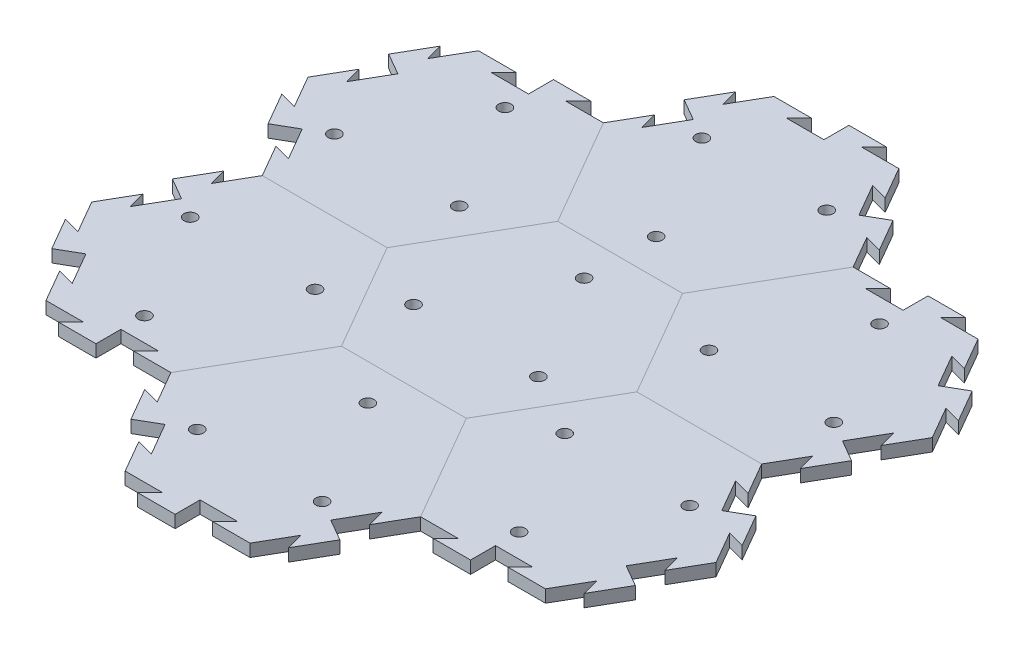
from build123d import *

# Parameters (mm, degrees)
BOSS_EXTRUDE1_DEPTH = 6.35
SKETCH9_R           = 3.175
CUT_EXTRUDE3_DEPTH  = 7.35
CIRPATTERN6_COUNT   = 3
CUT_EXTRUDE2_DEPTH  = 7.35
BOSS_EXTRUDE3_DEPTH = 6.35
CIRPATTERN3_COUNT   = 3
CIRPATTERN3_ANGLE   = 120
CIRPATTERN5_COUNT   = 6


with BuildPart() as part:
    # Sketch1 → Boss-Extrude1 (new body)
    with BuildSketch(Plane(origin=(0, 0, 0), x_dir=(1, 0, 0), z_dir=(0, 1, 0))):
        Polygon((63.5, 0), (31.75, 54.99261314), (-31.75, 54.99261314), (-63.5, 0), (-31.75, -54.99261314), (31.75, -54.99261314), align=None)
    extrude(amount=-BOSS_EXTRUDE1_DEPTH)

    # Sketch9 → Cut-Extrude3 (cut, through all)
    with BuildSketch(Plane(origin=(0, 0, 0), x_dir=(1, 0, 0), z_dir=(0, 1, 0))):
        with Locations((-31.75, -18.330871047)):
            Circle(SKETCH9_R)
    cut_extrude3 = extrude(amount=-CUT_EXTRUDE3_DEPTH, mode=Mode.SUBTRACT)

    # CirPattern6: Cut-Extrude3 ×3 about axis
    cirpattern6_axis = Axis((0, 0, 0), (0, 1, 0))
    for i in range(1, CIRPATTERN6_COUNT):
        add(cut_extrude3.rotate(cirpattern6_axis, i * 360 / CIRPATTERN6_COUNT), mode=Mode.SUBTRACT)


with BuildPart() as body_2:
    # Mirror1: mirrored copy
    add(part.part.mirror(Plane(origin=(31.75, -6.35, 54.99261314), x_dir=(-0.5, 0, 0.866025404), z_dir=(0.866025404, 0, 0.5))))

    # Sketch5 → Cut-Extrude2 (cut, through all)
    with BuildSketch(Plane(origin=(0, 0, 0), x_dir=(1, 0, 0), z_dir=(0, 1, 0))):
        Polygon((136.525, -16.497783942), (127.850738686, -14.173522628), (137.375738686, -30.67130657), (142.875, -27.49630657), align=None)
    cut_extrude2 = extrude(amount=-CUT_EXTRUDE2_DEPTH, mode=Mode.SUBTRACT)

    # Sketch7 → Boss-Extrude3 (add)
    with BuildSketch(Plane(origin=(0, 0, 0), x_dir=(1, 0, 0), z_dir=(0, 1, 0))):
        Polygon((142.875, -27.49630657), (148.374261314, -24.32130657), (157.899261314, -40.819090512), (149.225, -38.494829198), align=None)
    boss_extrude3 = extrude(amount=-BOSS_EXTRUDE3_DEPTH)

    # CirPattern3: Cut-Extrude2, Boss-Extrude3 ×3 about axis
    cirpattern3_axis = Axis((95.25, 0, 54.99261314), (0, -1, 0))
    for i in range(1, CIRPATTERN3_COUNT):
        add(cut_extrude2.rotate(cirpattern3_axis, i * CIRPATTERN3_ANGLE / (CIRPATTERN3_COUNT - 1)), mode=Mode.SUBTRACT)
        add(boss_extrude3.rotate(cirpattern3_axis, i * CIRPATTERN3_ANGLE / (CIRPATTERN3_COUNT - 1)))


with BuildPart() as cirpattern5_1:
    # CirPattern5: pattern copy
    add(body_2.part.rotate(Axis((0, 0, 0), (0, 1, 0)), 1 * 360 / CIRPATTERN5_COUNT))


with BuildPart() as cirpattern5_2:
    # CirPattern5: pattern copy
    add(body_2.part.rotate(Axis((0, 0, 0), (0, 1, 0)), 2 * 360 / CIRPATTERN5_COUNT))


with BuildPart() as cirpattern5_3:
    # CirPattern5: pattern copy
    add(body_2.part.rotate(Axis((0, 0, 0), (0, 1, 0)), 3 * 360 / CIRPATTERN5_COUNT))


with BuildPart() as cirpattern5_4:
    # CirPattern5: pattern copy
    add(body_2.part.rotate(Axis((0, 0, 0), (0, 1, 0)), 4 * 360 / CIRPATTERN5_COUNT))


with BuildPart() as cirpattern5_5:
    # CirPattern5: pattern copy
    add(body_2.part.rotate(Axis((0, 0, 0), (0, 1, 0)), 5 * 360 / CIRPATTERN5_COUNT))


solid = Compound([part.part, body_2.part, cirpattern5_1.part, cirpattern5_2.part, cirpattern5_3.part, cirpattern5_4.part, cirpattern5_5.part])
